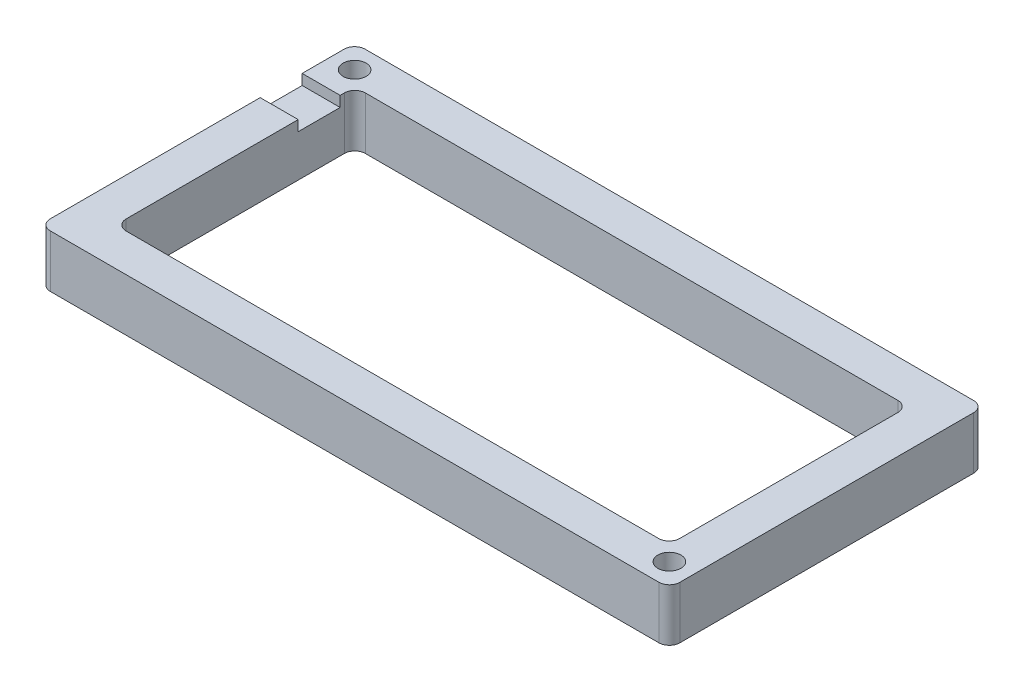
from build123d import *

# Parameters (mm, degrees)
SKETCH1_W           = 152.4
SKETCH1_H           = 76.2
BOSS_EXTRUDE1_DEPTH = 12.7
FILLET1_R           = 2.54
SKETCH3_W           = 133.99496637
SKETCH3_H           = 57.912
CUT_EXTRUDE4_DEPTH  = 13.7
FILLET2_R           = 2.54
SKETCH2_W           = 10.16
SKETCH2_H           = 2.54
CUT_EXTRUDE5_DEPTH  = 12.7
SKETCH4_R           = 2.794
CUT_EXTRUDE6_DEPTH  = 12.7
SKETCH5_R           = 2.794
CUT_EXTRUDE7_DEPTH  = 12.7


with BuildPart() as part:
    # Sketch1 → Boss-Extrude1 (new body)
    with BuildSketch(Plane(origin=(0, 0, 0), x_dir=(1, 0, 0), z_dir=(0, 1, 0))):
        Rectangle(SKETCH1_W, SKETCH1_H)
    extrude(amount=BOSS_EXTRUDE1_DEPTH)

    # Fillet1
    fillet1_edges = [part.edges().sort_by_distance(p)[0] for p in [
        (76.2, 6.35, 38.1),
        (-76.2, 6.35, 38.1),
        (-76.2, 6.35, -38.1),
        (76.2, 6.35, -38.1),
    ]]
    fillet(fillet1_edges, radius=FILLET1_R)

    # Sketch3 → Cut-Extrude4 (cut, through all)
    with BuildSketch(Plane(origin=(0, 0, 0), x_dir=(1, 0, 0), z_dir=(0, 1, 0))):
        Rectangle(SKETCH3_W, SKETCH3_H)
    extrude(amount=CUT_EXTRUDE4_DEPTH, mode=Mode.SUBTRACT)

    # Fillet2
    fillet2_edges = [part.edges().sort_by_distance(p)[0] for p in [
        (66.997483185, 6.35, 28.956),
        (66.997483185, 6.35, -28.956),
        (-66.997483185, 6.35, -28.956),
        (-66.997483185, 6.35, 28.956),
    ]]
    fillet(fillet2_edges, radius=FILLET2_R)

    # Sketch2 → Cut-Extrude5 (cut)
    with BuildSketch(Plane.ZY.offset(76.2)):
        with Locations((-20.32, 11.43)):
            Rectangle(SKETCH2_W, SKETCH2_H)
    extrude(amount=-CUT_EXTRUDE5_DEPTH, mode=Mode.SUBTRACT)

    # Sketch4 → Cut-Extrude6 (cut)
    with BuildSketch(Plane(origin=(0, 0, 0), x_dir=(1, 0, 0), z_dir=(0, 1, 0))):
        with Locations((-70.612, 32.512)):
            Circle(SKETCH4_R)
    extrude(amount=CUT_EXTRUDE6_DEPTH, mode=Mode.SUBTRACT)

    # Sketch5 → Cut-Extrude7 (cut)
    with BuildSketch(Plane(origin=(0, 0, 0), x_dir=(1, 0, 0), z_dir=(0, 1, 0))):
        with Locations((70.612, -32.512)):
            Circle(SKETCH5_R)
    extrude(amount=CUT_EXTRUDE7_DEPTH, mode=Mode.SUBTRACT)


solid = part.part
